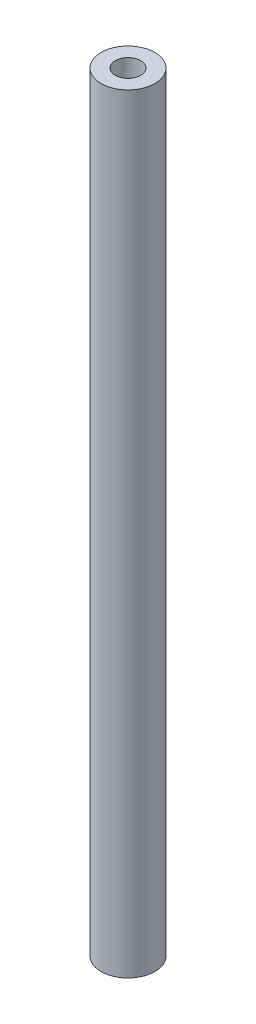
from build123d import *

# Parameters (mm, degrees)
SKETCH1_R           = 10.5
SKETCH1_R_2         = 4.963790091
BOSS_EXTRUDE1_DEPTH = 300


with BuildPart() as part:
    # Sketch1 → Boss-Extrude1 (new body)
    with BuildSketch(Plane(origin=(0, 0, 0), x_dir=(1, 0, 0), z_dir=(0, 1, 0))):
        Circle(SKETCH1_R)
        Circle(SKETCH1_R_2, mode=Mode.SUBTRACT)
    extrude(amount=BOSS_EXTRUDE1_DEPTH)


solid = part.part
